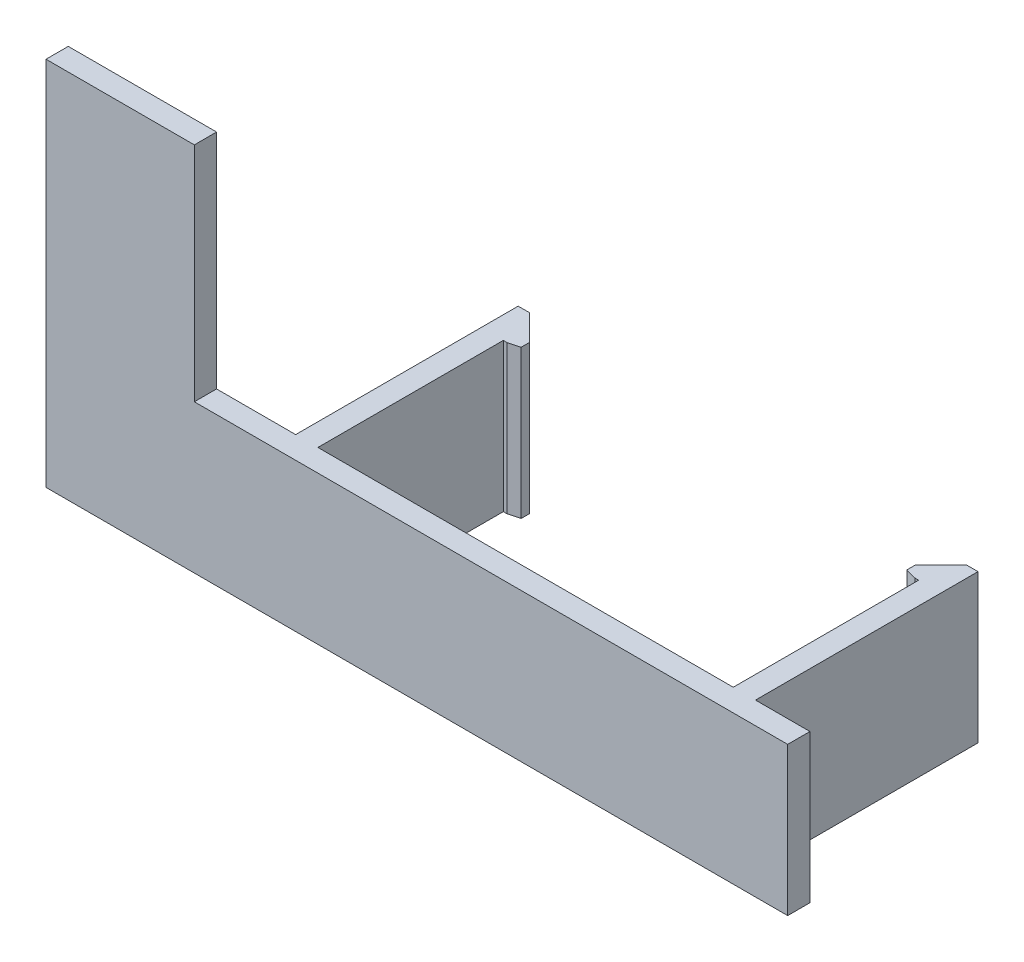
from build123d import *

# Parameters (mm, degrees)
BOSS_EXTRU_1_DEPTH            = 3
ESQUISSE2_W                   = 3
ESQUISSE2_H                   = 20
BOSS_EXTRU_2_DEPTH            = 30
ESQUISSE3_W                   = 5
ESQUISSE3_H                   = 20
BOSS_EXTRU_3_DEPTH            = 2
CHANFREIN1_SIZE               = 3.5
CHANFREIN2_SIZE               = 1.5
CHANFREIN2_SIZE2              = 0.401923789
CHANFREIN1_OF_SYM_TRIE1_SIZE  = 3.5
CHANFREIN2_OF_SYM_TRIE1_SIZE2 = 1.5
CHANFREIN2_OF_SYM_TRIE1_SIZE  = 0.401923789


with BuildPart() as part:
    # Esquisse1 → Boss.-Extru.1 (new body)
    with BuildSketch(Plane.XY):
        Polygon((-50, 0), (-50, -50), (50, -50), (50, -30), (-30, -30), (-30, 0), align=None)
    extrude(amount=BOSS_EXTRU_1_DEPTH)

    # Esquisse2 → Boss.-Extru.2 (add)
    with BuildSketch(Plane(origin=(0, 0, 0), x_dir=(-1, 0, 0), z_dir=(0, 0, -1))):
        with Locations((-41.161947113, -40)):
            Rectangle(ESQUISSE2_W, ESQUISSE2_H)
    boss_extru_2 = extrude(amount=BOSS_EXTRU_2_DEPTH)

    # Esquisse3 → Boss.-Extru.3 (add)
    with BuildSketch(Plane.ZY.offset(-39.661947113)):
        with Locations((-27.5, -40)):
            Rectangle(ESQUISSE3_W, ESQUISSE3_H)
    boss_extru_3 = extrude(amount=BOSS_EXTRU_3_DEPTH)

    # Chanfrein1
    chanfrein1_edges = [part.edges().sort_by_distance(p)[0] for p in [
        (37.661947113, -40, -30),
    ]]
    chamfer(chanfrein1_edges, length=CHANFREIN1_SIZE)

    # Chanfrein2
    chanfrein2_edges = [part.edges().sort_by_distance(p)[0] for p in [
        (37.661947113, -40, -25),
    ]]
    chanfrein2_side = [part.faces().sort_by_distance(p)[0] for p in [
        (38.661947113, -40, -25),
    ]]
    chamfer(chanfrein2_edges, length=CHANFREIN2_SIZE, length2=CHANFREIN2_SIZE2, reference=chanfrein2_side[0])

    # Symétrie1: Boss.-Extru.2, Boss.-Extru.3 across plane
    add(boss_extru_2.mirror(Plane.ZY.offset(-11.661947113)))
    add(boss_extru_3.mirror(Plane.ZY.offset(-11.661947113)))

    # Chanfrein1 of Symétrie1
    chanfrein1_of_sym_trie1_edges = [part.edges().sort_by_distance(p)[0] for p in [
        (-14.338052887, -40, -30),
    ]]
    chamfer(chanfrein1_of_sym_trie1_edges, length=CHANFREIN1_OF_SYM_TRIE1_SIZE)

    # Chanfrein2 of Symétrie1
    chanfrein2_of_sym_trie1_edges = [part.edges().sort_by_distance(p)[0] for p in [
        (-14.338052887, -40, -25),
    ]]
    chamfer(chanfrein2_of_sym_trie1_edges, length=CHANFREIN2_OF_SYM_TRIE1_SIZE, length2=CHANFREIN2_OF_SYM_TRIE1_SIZE2)


solid = part.part
